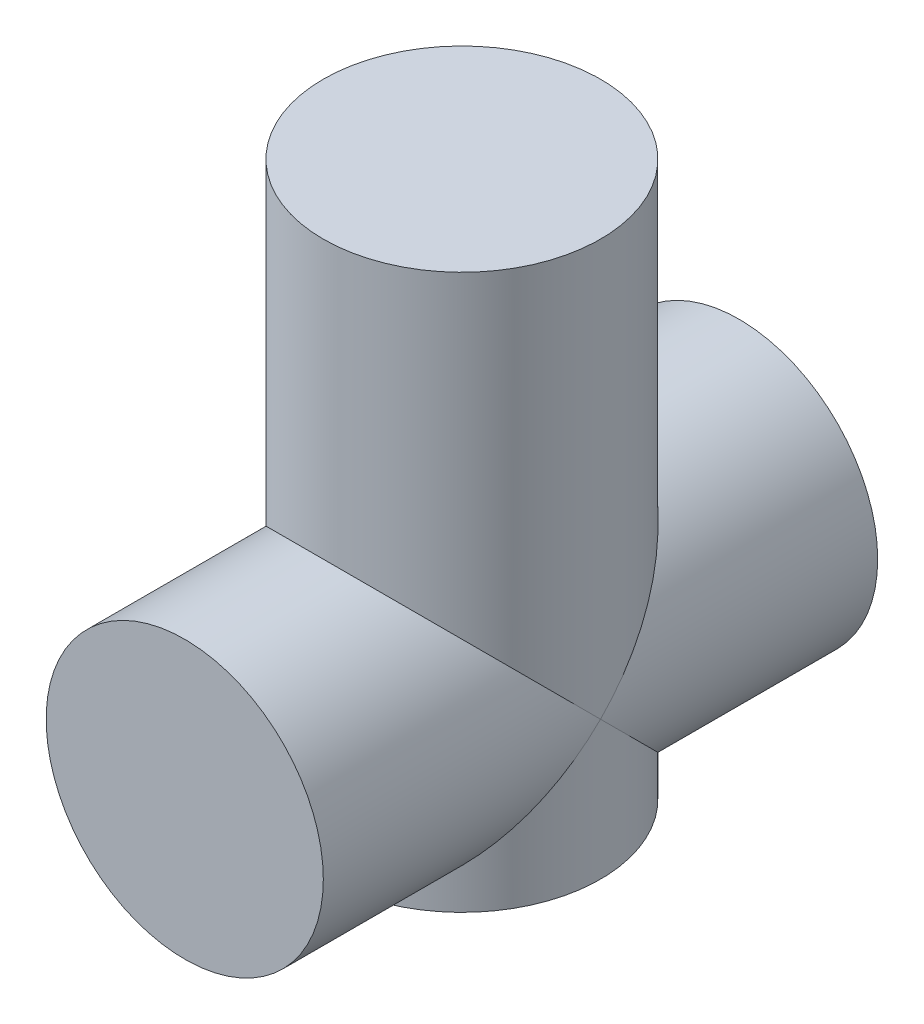
from build123d import *

# Parameters (mm, degrees)
SKETCH1_R                = 25
BOSS_EXTRUDE1_DEPTH      = 100
BOSS_EXTRUDE2_DEPTH      = 50
BOSS_EXTRUDE2_DEPTH_BACK = 50
SKETCH2_R                = 25


with BuildPart() as part:
    # Sketch1 → Boss-Extrude1 (new body)
    with BuildSketch(Plane(origin=(0, 0, 0), x_dir=(1, 0, 0), z_dir=(0, 1, 0))):
        Circle(SKETCH1_R)
    extrude(amount=BOSS_EXTRUDE1_DEPTH)

    # Sketch2 → Boss-Extrude2 (add, two sides: drawn at the far end of the back side and taken through both)
    with BuildSketch(Plane.XY.offset(-BOSS_EXTRUDE2_DEPTH_BACK)):
        with Locations((0, 25)):
            Circle(SKETCH2_R)
    extrude(amount=BOSS_EXTRUDE2_DEPTH + BOSS_EXTRUDE2_DEPTH_BACK)


solid = part.part
